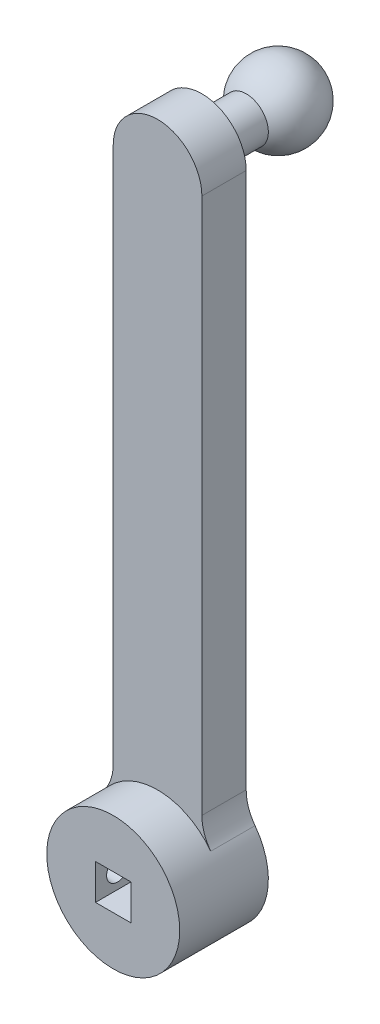
from build123d import *

# Parameters (mm, degrees)
SKETCH1_R           = 9.525
BOSS_EXTRUDE1_DEPTH = 12.7
SKETCH2_W           = 5.08
SKETCH2_H           = 5.08
CUT_EXTRUDE2_DEPTH  = 6.35
BOSS_EXTRUDE2_DEPTH = 6.35
FILLET2_R           = 6.35
CUT_EXTRUDE3_REACH  = 14.065
SKETCH5_R           = 1.5875
SKETCH4_R           = 3.175
BOSS_EXTRUDE3_DEPTH = 6.35
DOME1_FACE_RADIUS   = 3.175
DOME1_HEIGHT        = 10.16


with BuildPart() as part:
    # Sketch1 → Boss-Extrude1 (new body)
    with BuildSketch(Plane.XY):
        Circle(SKETCH1_R)
    extrude(amount=BOSS_EXTRUDE1_DEPTH)

    # Sketch2 → Cut-Extrude2 (cut)
    with BuildSketch(Plane.XY.offset(12.7)):
        Rectangle(SKETCH2_W, SKETCH2_H)
    extrude(amount=-CUT_EXTRUDE2_DEPTH, mode=Mode.SUBTRACT)

    # Sketch3 → Boss-Extrude2 (add)
    with BuildSketch(Plane(origin=(0, 0, 0), x_dir=(-1, 0, 0), z_dir=(0, 0, -1))):
        with BuildLine():
            Line((-6.35, 10.172076103), (-6.35, 7.099515829))
            Line((-6.35, 7.099515829), (6.35, 7.099515829))
            Line((6.35, 7.099515829), (6.35, 10.172076103))
            Line((6.35, 10.172076103), (6.35, 86.372076103))
            ThreePointArc((6.35, 86.372076103), (0, 92.722076103), (-6.35, 86.372076103))
            Line((-6.35, 86.372076103), (-6.35, 10.172076103))
        make_face()
    extrude(amount=-BOSS_EXTRUDE2_DEPTH)

    # Fillet2
    fillet2_edges = [part.edges().sort_by_distance(p)[0] for p in [
        (-6.35, 7.099515829, 3.175),
        (6.35, 7.099515829, 3.175),
    ]]
    fillet(fillet2_edges, radius=FILLET2_R)

    # Sketch5 → Cut-Extrude3 (cut, up to next)
    with BuildSketch(Plane.ZY.offset(-2.54), mode=Mode.PRIVATE) as cut_extrude3_sk1:
        with Locations((9.525, 0)):
            Circle(SKETCH5_R)
    cut_extrude3_tool1 = extrude(cut_extrude3_sk1.sketch, amount=CUT_EXTRUDE3_REACH, mode=Mode.PRIVATE) & part.part
    add(cut_extrude3_tool1.solids().sort_by_distance((2.54, 0, 9.525))[0], mode=Mode.SUBTRACT)

    # Sketch4 → Boss-Extrude3 (add)
    with BuildSketch(Plane(origin=(0, 0, 0), x_dir=(-1, 0, 0), z_dir=(0, 0, -1))):
        with Locations((0, 86.372076103)):
            Circle(SKETCH4_R)
    extrude(amount=BOSS_EXTRUDE3_DEPTH)

    # Dome1: a dome of height H over a round flat face of radius A is a cap of a sphere of radius (A * A + H * H) / (2 * H)
    dome1_r = (DOME1_FACE_RADIUS * DOME1_FACE_RADIUS + DOME1_HEIGHT * DOME1_HEIGHT) / (2 * DOME1_HEIGHT)
    dome1_base = Plane((0, 86.372076103, -6.35), z_dir=(0, 0, -1))
    with Locations(dome1_base.offset(DOME1_HEIGHT - dome1_r)):
        dome1_ball = Sphere(dome1_r, mode=Mode.PRIVATE)
    add(split(dome1_ball, bisect_by=dome1_base, keep=Keep.TOP, mode=Mode.PRIVATE))


solid = part.part
